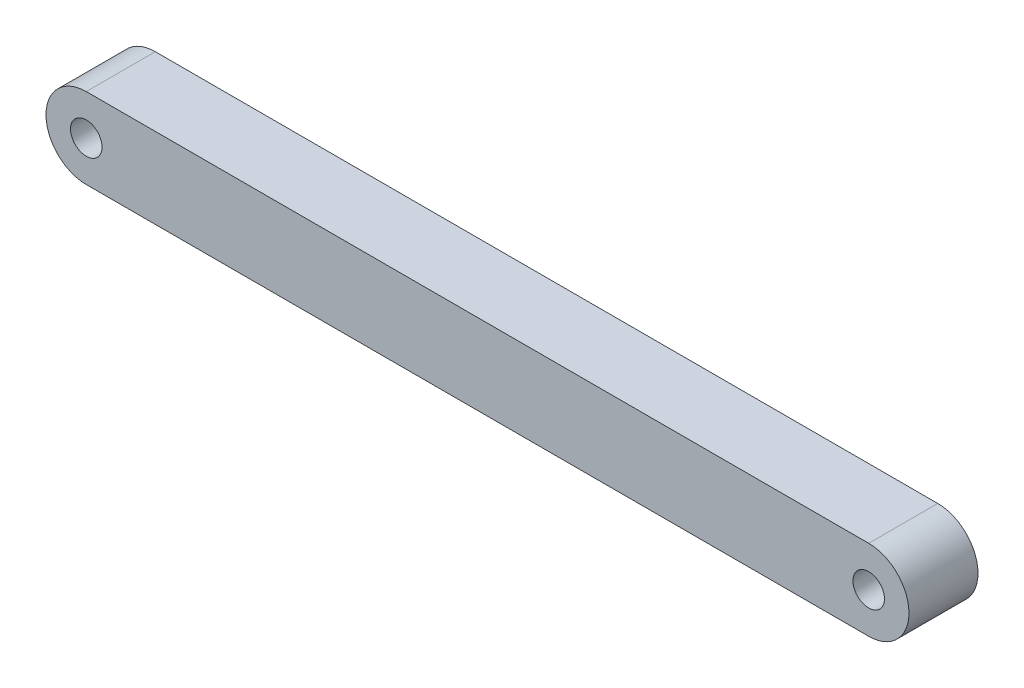
from build123d import *

# Parameters (mm, degrees)
BOSS_EXTRUDE1_DEPTH = 7.62
CUT_EXTRUDE1_START  = -8.62
SKETCH2_R           = 1.7399
CUT_EXTRUDE1_DEPTH  = 9.62


with BuildPart() as part:
    # Sketch1 → Boss-Extrude1 (new body)
    with BuildSketch(Plane.XY):
        with BuildLine():
            Line((0, 4.445), (86.36, 4.445))
            ThreePointArc((86.36, 4.445), (90.805, 0), (86.36, -4.445))
            Line((86.36, -4.445), (0, -4.445))
            ThreePointArc((0, -4.445), (-4.445, 0), (0, 4.445))
        make_face()
    extrude(amount=BOSS_EXTRUDE1_DEPTH)

    # Sketch2 → Cut-Extrude1 (cut)
    with BuildSketch(Plane.XY.offset(7.62).offset(CUT_EXTRUDE1_START)):
        Circle(SKETCH2_R)
    cut_extrude1 = extrude(amount=CUT_EXTRUDE1_DEPTH, mode=Mode.SUBTRACT)

    # Mirror1: Cut-Extrude1 across plane
    add(cut_extrude1.mirror(Plane(origin=(43.18, 0, 0), x_dir=(0, 0, 1), z_dir=(1, 0, 0))), mode=Mode.SUBTRACT)


solid = part.part
